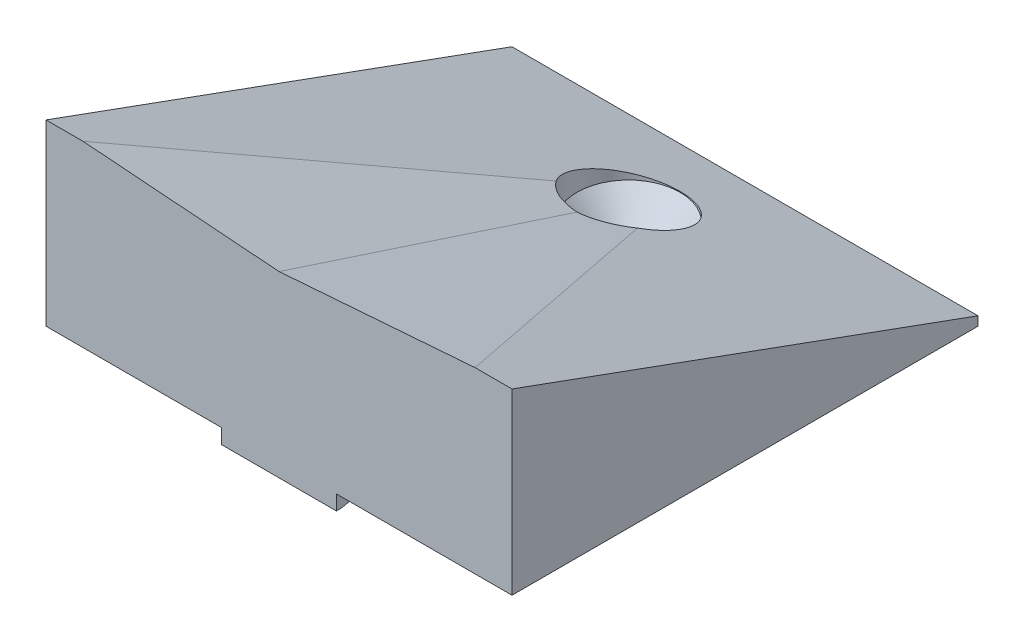
from build123d import *

# Parameters (mm, degrees)
BOSS_EXTRUDE1_DEPTH = 16
BOSS_EXTRUDE2_REACH = 39.169
SKETCH6_W           = 32
SKETCH6_H           = 7.878
SKETCH6_R           = 3.5433
SKETCH7_R           = 1.7992
SKETCH7_R_2         = 3.9492
BOSS_EXTRUDE3_DEPTH = 1.016
CUT_EXTRUDE1_DEPTH  = 40.8462222


with BuildPart() as part:
    # Sketch1 → Boss-Extrude1 (new, symmetric)
    with BuildSketch(Plane(origin=(0, 0, 0), x_dir=(0, 0, -1), z_dir=(1, 0, 0))):
        Polygon((19.808, 5.059429759), (19.808, 2.192072254), (27.686, 2.192072254), (32, 0.621904663), (32, 0), (0, 0), (0, 12.26895216), align=None)
    extrude(amount=BOSS_EXTRUDE1_DEPTH, both=True)

    # Sketch5 → CSK for _6 Flat Head Machine Screw1 (revolve, cut)
    with BuildSketch(Plane(origin=(0, 2.192072254, -24), x_dir=(0, 0, 1), z_dir=(1, 0, 0))):
        Polygon((0, 0), (0, 2.192072254), (1.89865, 2.192072254), (1.89865, 1.891953401), (3.5433, 0), align=None)
    revolve(axis=Axis((0, 8.542072254, -24), (0, -1, 0)), mode=Mode.SUBTRACT)

    # Boss-Extrude2: up to this face of the body (flat: up to its plane)
    boss_extrude2_end = Plane(part.part.faces().sort_by_distance((0, 8.664190959, -9.904))[0])
    # Sketch6 → Boss-Extrude2 (add, up to the picked face)
    with BuildSketch(Plane(origin=(0, 2.192072254, 0), x_dir=(1, 0, 0), z_dir=(0, 1, 0)), mode=Mode.PRIVATE) as boss_extrude2_sk1:
        with Locations((0, 23.747)):
            Rectangle(SKETCH6_W, SKETCH6_H)
        with Locations((0, 24)):
            Circle(SKETCH6_R, mode=Mode.SUBTRACT)
    boss_extrude2_tool1 = split(extrude(boss_extrude2_sk1.sketch, amount=BOSS_EXTRUDE2_REACH, mode=Mode.PRIVATE), bisect_by=boss_extrude2_end, keep=Keep.BOTH, mode=Mode.PRIVATE)
    add(boss_extrude2_tool1.solids().sort_by(Axis((-15.670445, 2.192072, -23.747), (0, 1, 0)))[0])

    # Sketch7 → Boss-Extrude3 (add)
    with BuildSketch(Plane.XZ):
        with Locations((8, -16)):
            Circle(SKETCH7_R)
        with Locations((0, -16)):
            Circle(SKETCH7_R_2)
        with Locations((-8, -16)):
            Circle(SKETCH7_R)
        with Locations((0, -8)):
            Circle(SKETCH7_R)
        with BuildLine():
            Line((3.9492, 0), (-3.9492, 0))
            ThreePointArc((-3.9492, 0), (0, -3.9492), (3.9492, 0))
        make_face()
    extrude(amount=BOSS_EXTRUDE3_DEPTH)

    # Sketch9 → Cut-Extrude1 (cut, through all, along a direction that is not the sketch's normal)
    with BuildSketch(Plane.XY):
        Polygon((-13.46, 12.26895216), (0, 11.25295216), (13.46, 12.26895216), align=None)
    extrude(amount=-CUT_EXTRUDE1_DEPTH, dir=(0, 0.3108760554921047, 0.9504504606352032), mode=Mode.SUBTRACT)


solid = part.part
